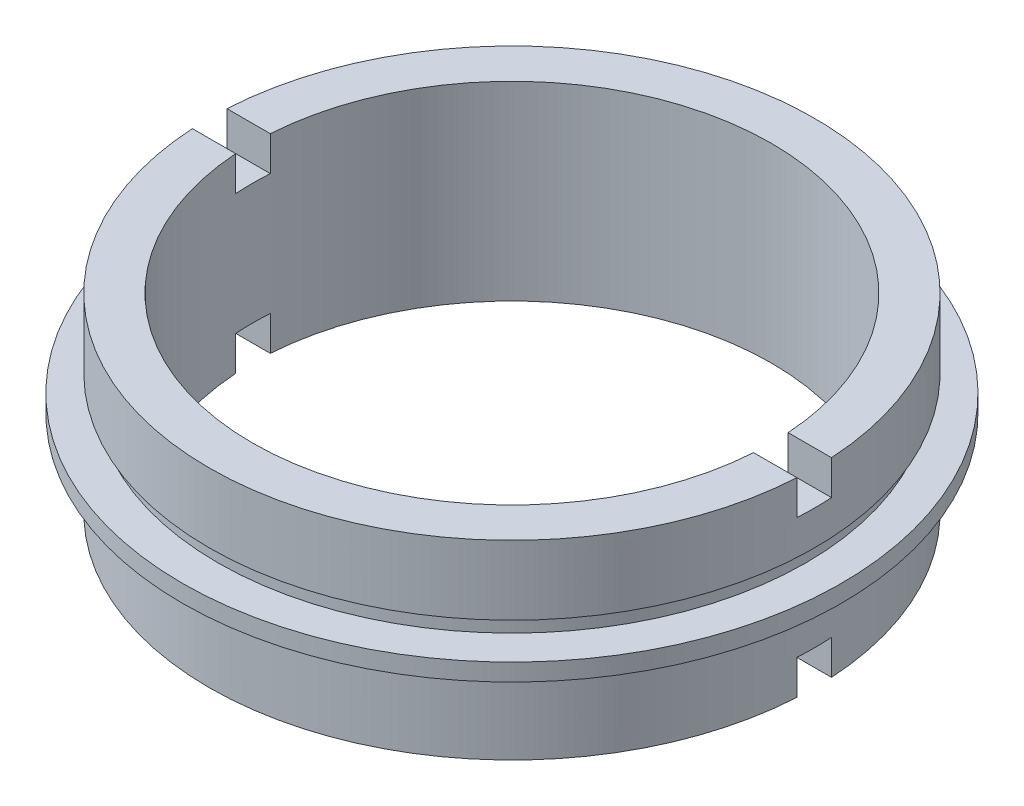
from build123d import *

# Parameters (mm, degrees)
SKETCH_2_W          = 2
SKETCH_2_H          = 4.593987872
SKETCH_2_H_2        = 6.667892238
CUT_EXTRUDE_1_DEPTH = 39.5


with BuildPart() as part:
    # 草图1 → 旋转1 (revolve)
    with BuildSketch(Plane.XY, mode=Mode.PRIVATE) as revolve_1_sk:
        Polygon((-15, 11), (-17.5, 11), (-17.5, 7), (-17, 7), (-17, 6), (-19.05, 6), (-19.05, 5), (-17, 5), (-17, 4), (-17.5, 4), (-17.5, 0), (-15, 0), align=None)
    revolve(revolve_1_sk.sketch.rotate(Axis((0, 22.677499451, 0), (0, -1, 0)), 270), axis=Axis((0, 22.677499451, 0), (0, -1, 0)))  # turned: the seam where the file's is

    # 草图2 → 切除-拉伸1 (cut, symmetric)
    with BuildSketch(Plane(origin=(0, 0, 0), x_dir=(0, 0, -1), z_dir=(1, 0, 0))):
        with Locations((0, 11.296993936)):
            Rectangle(SKETCH_2_W, SKETCH_2_H)
        with Locations((0, -1.333946119)):
            Rectangle(SKETCH_2_W, SKETCH_2_H_2)
    extrude(amount=CUT_EXTRUDE_1_DEPTH, both=True, mode=Mode.SUBTRACT)


solid = part.part
